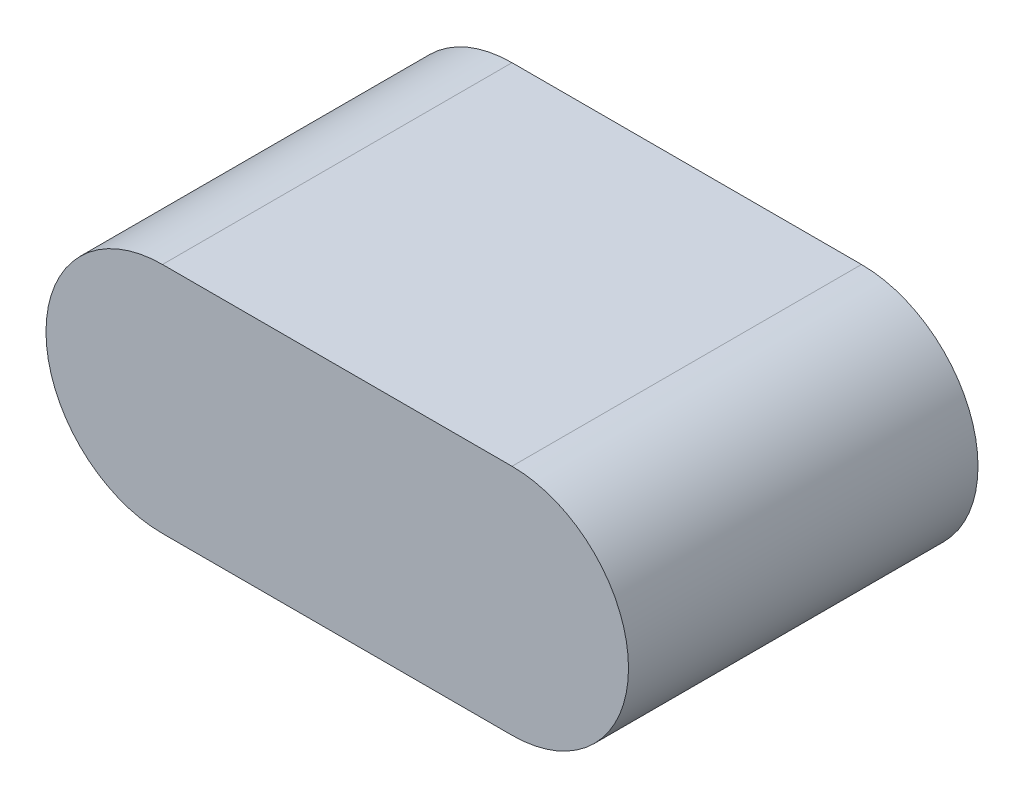
from build123d import *

# Parameters (mm, degrees)
EXTRUDE_1_DEPTH = 6


with BuildPart() as part:
    # Эскиз1 → Бобышка-Вытянуть1 (new body)
    with BuildSketch(Plane.XY):
        with BuildLine():
            Line((-3.518958198, 2), (2.481041802, 2))
            ThreePointArc((2.481041802, 2), (4.481041802, 0), (2.481041802, -2))
            Line((2.481041802, -2), (-3.518958198, -2))
            ThreePointArc((-3.518958198, -2), (-5.518958198, 0), (-3.518958198, 2))
        make_face()
    extrude(amount=EXTRUDE_1_DEPTH)


solid = part.part
